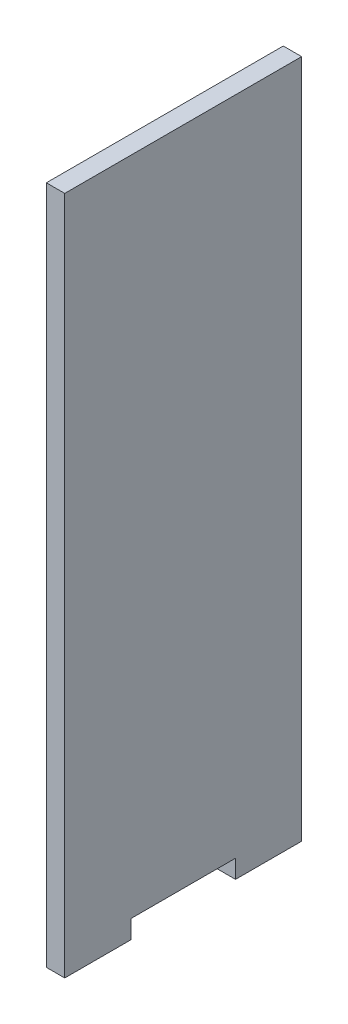
from build123d import *

# Parameters (mm, degrees)
BOSS_EXTRUDE1_DEPTH = 5


with BuildPart() as part:
    # Sketch1 → Boss-Extrude1 (new body)
    with BuildSketch(Plane(origin=(0, 0, 0), x_dir=(0, 0, -1), z_dir=(1, 0, 0))):
        Polygon((-32.25, 180), (32.25, 180), (32.25, 0), (32.25, -5), (14.25, -5), (14.25, 0), (-14.25, 0), (-14.25, -5), (-32.25, -5), (-32.25, 0), align=None)
    extrude(amount=BOSS_EXTRUDE1_DEPTH)


solid = part.part
